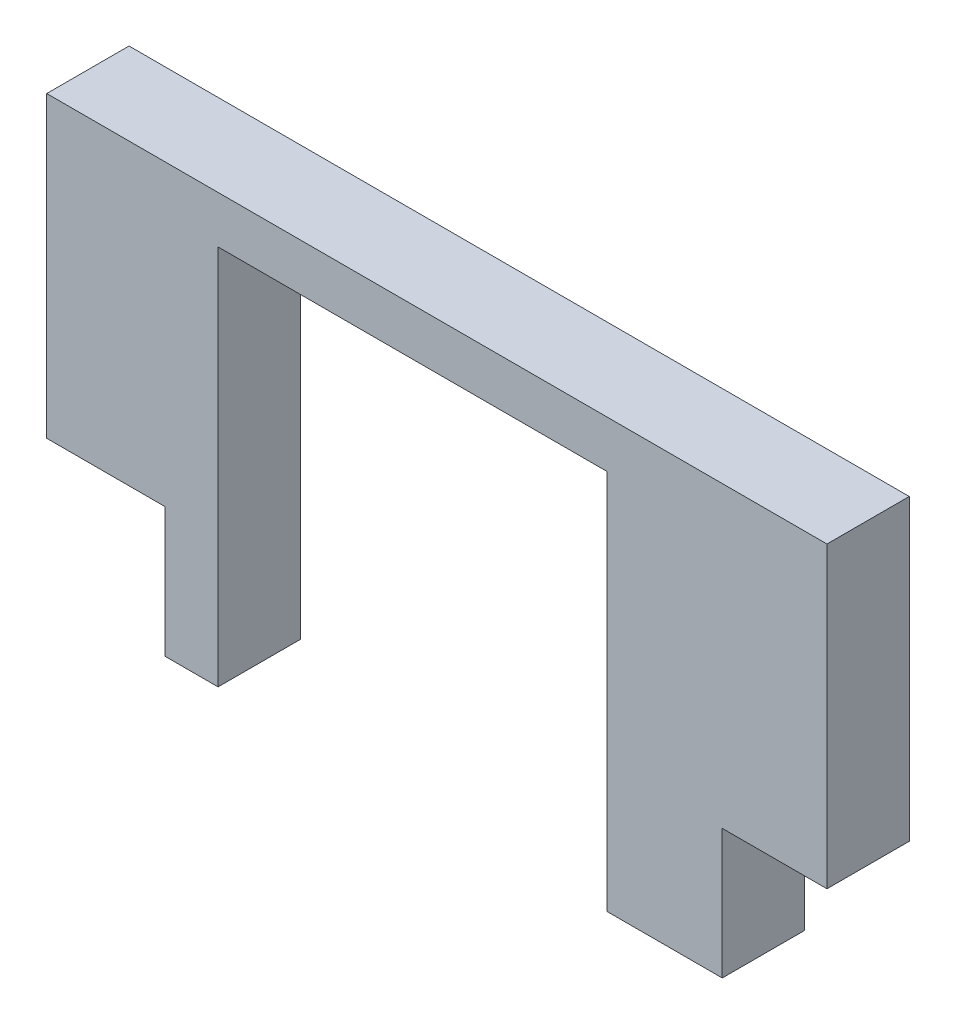
from build123d import *

# Parameters (mm, degrees)
BOSS_EXTRUDE1_DEPTH = 3.175


with BuildPart() as part:
    # Sketch1 → Boss-Extrude1 (new body)
    with BuildSketch(Plane.XY):
        Polygon((0, 16.66), (30.1, 16.66), (30.1, 6.34), (30.1, 5.14), (26.06, 5.14), (26.06, 0.14), (25.36, 0.14), (21.61, 0.14), (21.61, 5.14), (21.61, 6.34), (21.61, 14.84), (6.61, 14.84), (6.61, 6.34), (6.61, 5.14), (6.61, 0.14), (4.559999976, 0.14), (4.559999976, 5.14), (0, 5.14), (0, 6.34), align=None)
    extrude(amount=-BOSS_EXTRUDE1_DEPTH)


solid = part.part
